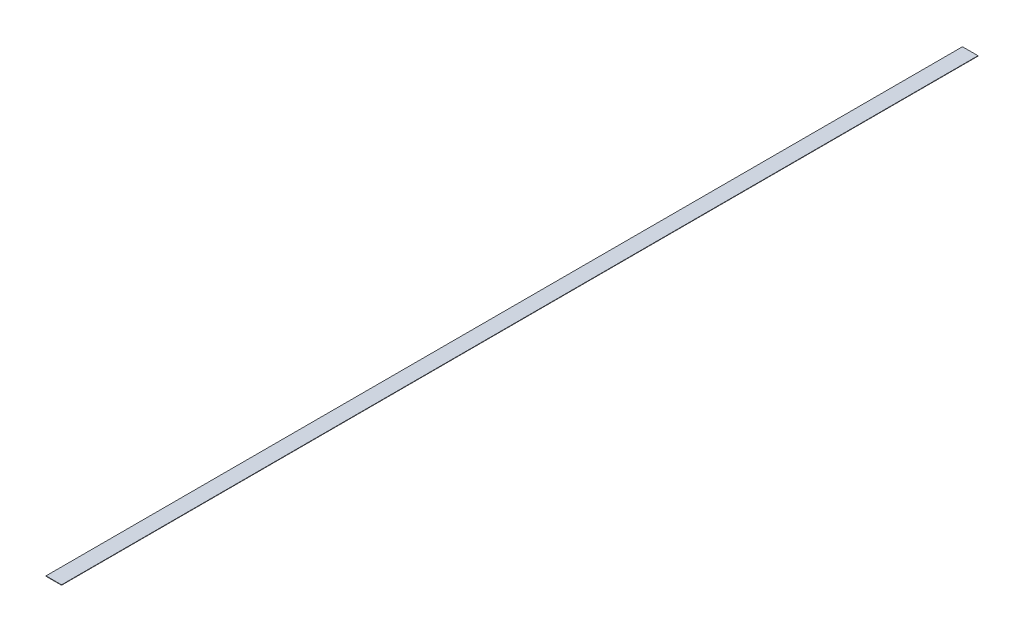
from build123d import *

# Parameters (mm, degrees)
SKETCH1_W           = 50.8
SKETCH1_H           = 2997.2
BOSS_EXTRUDE1_DEPTH = 1.27


with BuildPart() as part:
    # Sketch1 → Boss-Extrude1 (new body)
    with BuildSketch(Plane(origin=(0, 0, 0), x_dir=(1, 0, 0), z_dir=(0, 1, 0))):
        with Locations((0, 1498.6)):
            Rectangle(SKETCH1_W, SKETCH1_H)
    extrude(amount=BOSS_EXTRUDE1_DEPTH)


solid = part.part
